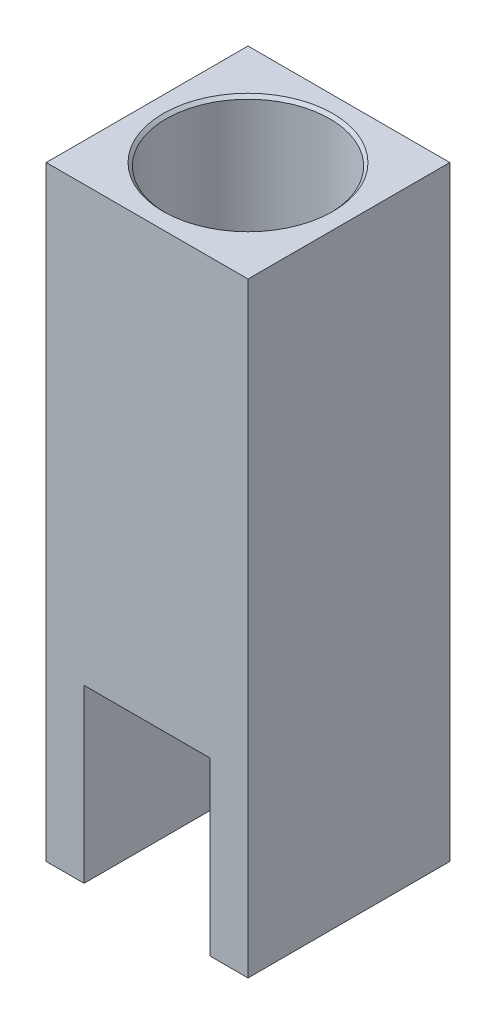
from build123d import *

# Parameters (mm, degrees)
SKETCH1_W                  = 50.8
SKETCH1_H                  = 50.8
BOSS_EXTRUDE1_DEPTH        = 152.4
SKETCH2_R                  = 6.1468
CUT_EXTRUDE1_DEPTH         = 153.4
SKETCH3_R                  = 20.5994
CUT_EXTRUDE2_DEPTH         = 74.93
SKETCH4_R                  = 17.78
CUT_EXTRUDE3_DEPTH         = 82.55
CUT_EXTRUDE4_DEPTH         = 42.4434
SKETCH6_R                  = 9.144
CUT_EXTRUDE5_DEPTH         = 4.318
FILLET1_R                  = 6.35
F_10_24_TAPPED_HOLE1_D     = 3.7973
F_10_24_TAPPED_HOLE1_DEPTH = 17.78
F_10_24_TAPPED_HOLE1_TIP   = 1.140824014
CHAMFER1_SIZE              = 0.762


with BuildPart() as part:
    # Sketch1 → Boss-Extrude1 (new body)
    with BuildSketch(Plane(origin=(0, 0, 0), x_dir=(1, 0, 0), z_dir=(0, 1, 0))):
        with Locations((25.4, -25.4)):
            Rectangle(SKETCH1_W, SKETCH1_H)
    extrude(amount=BOSS_EXTRUDE1_DEPTH)

    # Sketch2 → Cut-Extrude1 (cut, through all)
    with BuildSketch(Plane(origin=(0, 152.4, 0), x_dir=(1, 0, 0), z_dir=(0, 1, 0))):
        with Locations((25.4, -25.4)):
            Circle(SKETCH2_R)
    extrude(amount=-CUT_EXTRUDE1_DEPTH, mode=Mode.SUBTRACT)

    # Sketch3 → Cut-Extrude2 (cut)
    with BuildSketch(Plane(origin=(0, 152.4, 0), x_dir=(1, 0, 0), z_dir=(0, 1, 0))):
        with Locations((25.4, -25.4)):
            Circle(SKETCH3_R)
    extrude(amount=-CUT_EXTRUDE2_DEPTH, mode=Mode.SUBTRACT)

    # Sketch4 → Cut-Extrude3 (cut)
    with BuildSketch(Plane(origin=(0, 152.4, 0), x_dir=(1, 0, 0), z_dir=(0, 1, 0))):
        with Locations((25.4, -25.4)):
            Circle(SKETCH4_R)
    extrude(amount=-CUT_EXTRUDE3_DEPTH, mode=Mode.SUBTRACT)

    # Sketch5 → Cut-Extrude4 (cut)
    with BuildSketch(Plane.XY.offset(50.8)):
        Polygon((9.525, 0), (9.525, 36.83), (9.525, 43.18), (15.875, 43.18), (34.925, 43.18), (41.275, 43.18), (41.275, 36.83), (41.275, 0), align=None)
    extrude(amount=-CUT_EXTRUDE4_DEPTH, mode=Mode.SUBTRACT)

    # Sketch6 → Cut-Extrude5 (cut)
    with BuildSketch(Plane.XZ.offset(-43.18)):
        with Locations((25.4, 25.4)):
            Circle(SKETCH6_R)
    extrude(amount=-CUT_EXTRUDE5_DEPTH, mode=Mode.SUBTRACT)

    # Fillet1
    fillet1_edges = [part.edges().sort_by_distance(p)[0] for p in [
        (9.525, 21.59, 8.3566),
        (41.275, 21.59, 8.3566),
    ]]
    fillet(fillet1_edges, radius=FILLET1_R)

    # #10-24 Tapped Hole1
    with Locations(Plane(origin=(0, 0, 0), x_dir=(-1, 0, 0), z_dir=(0, -1, 0))):
        with Locations((-6.35, -6.35), (-44.45, -6.35)):
            Hole(F_10_24_TAPPED_HOLE1_D / 2, depth=F_10_24_TAPPED_HOLE1_DEPTH)
            with Locations((0, 0, -(F_10_24_TAPPED_HOLE1_DEPTH + F_10_24_TAPPED_HOLE1_TIP / 2))):  # 118° drill point
                Cone(0, F_10_24_TAPPED_HOLE1_D / 2, F_10_24_TAPPED_HOLE1_TIP, mode=Mode.SUBTRACT)

    # Chamfer1
    chamfer1_edges = [part.edges().sort_by_distance(p)[0] for p in [
        (4.8006, 152.4, 25.4),
    ]]
    chamfer(chamfer1_edges, length=CHAMFER1_SIZE)


solid = part.part
